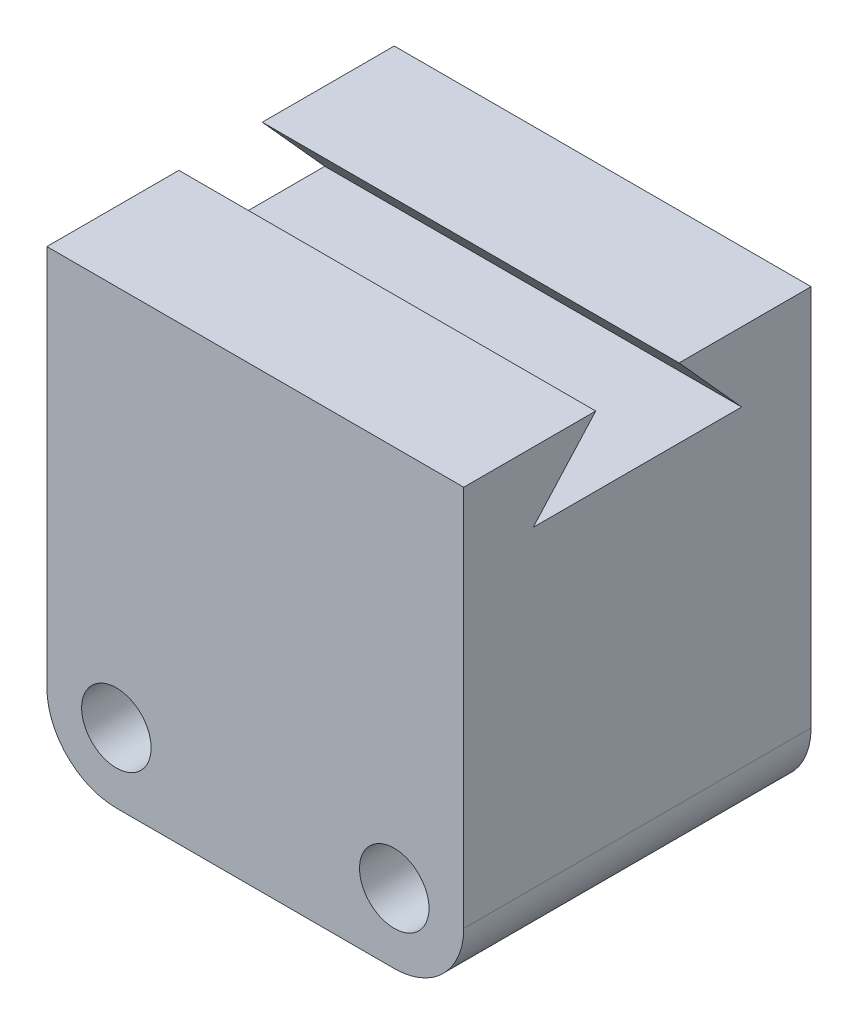
from build123d import *

# Parameters (mm, degrees)
SKETCH1_W           = 60
SKETCH1_H           = 65
BOSS_EXTRUDE1_DEPTH = 25
CUT_EXTRUDE1_DEPTH  = 60
SKETCH4_R           = 5
CUT_EXTRUDE2_DEPTH  = 51
FILLET1_R           = 10
SCALE1_SCALE        = 0.3


with BuildPart() as part:
    # Sketch1 → Boss-Extrude1 (new body, symmetric)
    with BuildSketch(Plane.XY):
        with Locations((-3.578258959, -17.200317296)):
            Rectangle(SKETCH1_W, SKETCH1_H)
    extrude(amount=BOSS_EXTRUDE1_DEPTH, both=True)

    # Sketch3 → Cut-Extrude1 (cut)
    with BuildSketch(Plane(origin=(26.421741041, 0, 0), x_dir=(0, 0, -1), z_dir=(1, 0, 0))):
        Polygon((-15, 5.299682704), (15, 5.299682704), (6, 15.299682704), (-6, 15.299682704), align=None)
    extrude(amount=-CUT_EXTRUDE1_DEPTH, mode=Mode.SUBTRACT)

    # Sketch4 → Cut-Extrude2 (cut, through all)
    with BuildSketch(Plane.XY.offset(25)):
        with Locations((16.421741041, -39.700317296)):
            Circle(SKETCH4_R)
        with Locations((-23.578258959, -39.700317296)):
            Circle(SKETCH4_R)
    extrude(amount=-CUT_EXTRUDE2_DEPTH, mode=Mode.SUBTRACT)

    # Fillet1
    fillet1_edges = [part.edges().sort_by_distance(p)[0] for p in [
        (26.421741041, -49.700317296, 0),
        (-33.578258959, -49.700317296, 0),
    ]]
    fillet(fillet1_edges, radius=FILLET1_R)


with BuildPart() as part_1:
    # Scale1: scaled about (-3.578258959, -17.756195099, 0)
    add(part.part.scale(SCALE1_SCALE).moved(Location((-2.504781271, -12.429336569, 0))))


solid = part_1.part
